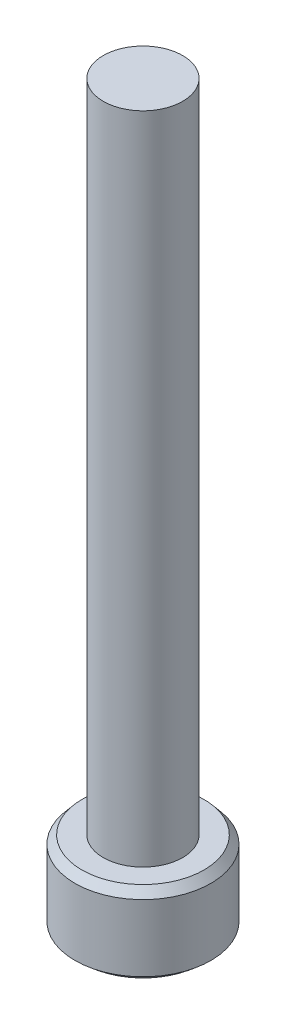
from build123d import *

# Parameters (mm, degrees)
SKETCH1_R             = 4.15
BOSS_EXTRUDE1_DEPTH   = 5
SKETCH2_R             = 2.425
BOSS_EXTRUDE2_DEPTH   = 40
CUT_EXTRUDE1_DEPTH    = 3
CHAMFER1_SIZE         = 0.5
CHAMFER1_SIZE2        = 0.419549816
CHAMFER1_PART_2_SIZE  = 0.5
CHAMFER1_PART_2_SIZE2 = 0.419549816


with BuildPart() as part:
    # Sketch1 → Boss-Extrude1 (new body)
    with BuildSketch(Plane(origin=(0, 0, 0), x_dir=(1, 0, 0), z_dir=(0, 1, 0))):
        Circle(SKETCH1_R)
    extrude(amount=BOSS_EXTRUDE1_DEPTH)

    # Sketch2 → Boss-Extrude2 (add)
    with BuildSketch(Plane(origin=(0, 5, 0), x_dir=(1, 0, 0), z_dir=(0, 1, 0))):
        Circle(SKETCH2_R)
    extrude(amount=BOSS_EXTRUDE2_DEPTH)

    # Sketch3 → Cut-Extrude1 (cut)
    with BuildSketch(Plane.XZ):
        Polygon((0, 2.786041865), (-2.412783031, 1.393020932), (-2.412783031, -1.393020932), (0, -2.786041865), (2.412783031, -1.393020932), (2.412783031, 1.393020932), align=None)
    extrude(amount=-CUT_EXTRUDE1_DEPTH, mode=Mode.SUBTRACT)

    # Chamfer1
    chamfer1_edges = [part.edges().sort_by_distance(p)[0] for p in [
        (-4.15, 0, 0),
    ]]
    chamfer1_side = [part.faces().sort_by_distance(p)[0] for p in [
        (-4.032620274, 0, 0),
    ]]
    chamfer(chamfer1_edges, length=CHAMFER1_SIZE, length2=CHAMFER1_SIZE2, reference=chamfer1_side[0])

    # Chamfer1 part 2
    chamfer1_part_2_edges = [part.edges().sort_by_distance(p)[0] for p in [
        (-4.15, 5, 0),
    ]]
    chamfer1_part_2_side = [part.faces().sort_by_distance(p)[0] for p in [
        (-4.15, 2.5, 0),
    ]]
    chamfer(chamfer1_part_2_edges, length=CHAMFER1_PART_2_SIZE, length2=CHAMFER1_PART_2_SIZE2, reference=chamfer1_part_2_side[0])


solid = part.part
